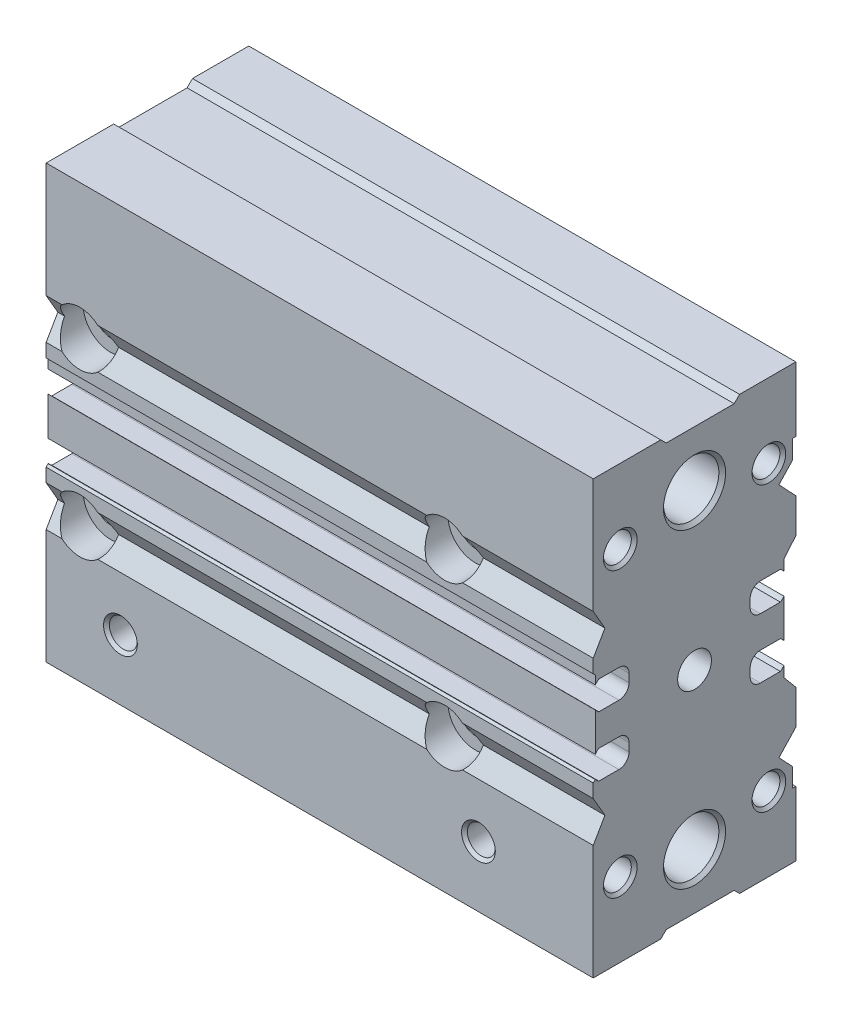
from build123d import *

# Parameters (mm, degrees)
BOSS_EXTRUDE1_DEPTH = 81
SKETCH10_W          = 50
SKETCH10_H          = 4.1


with BuildPart() as part:
    # Sketch1 → Boss-Extrude1 (new body)
    with BuildSketch(Plane(origin=(0, 0, 0), x_dir=(0, 0, -1), z_dir=(1, 0, 0))):
        with BuildLine():
            Line((-15, -32), (-5, -32))
            Line((-5, -32), (-4.2, -31.2))
            Line((-4.2, -31.2), (5.866666667, -31.2))
            Line((5.866666667, -31.2), (6.666666667, -32))
            Line((6.666666667, -32), (15, -32))
            Line((15, -32), (15, -22.434782609))
            Line((15, -22.434782609), (14.5, -22.434782609))
            Line((14.5, -22.434782609), (14.5, -19.633333333))
            Line((14.5, -19.633333333), (12.5, -17.5))
            Line((12.5, -17.5), (15, -14.833333333))
            Line((15, -14.833333333), (15, -9.714205686))
            Line((15, -9.714205686), (13.235294118, -7.611111111))
            Line((13.235294118, -7.611111111), (13.235294118, -6.044444444))
            ThreePointArc((13.235294118, -6.044444444), (12.988775356, -6.313226652), (12.706722689, -6.544444444))
            Line((12.706722689, -6.544444444), (9.735294118, -6.544444444))
            ThreePointArc((9.735294118, -6.544444444), (8.674633946, -6.105104616), (8.235294118, -5.044444444))
            Line((8.235294118, -5.044444444), (8.235294118, -3.844444444))
            ThreePointArc((8.235294118, -3.844444444), (8.674633946, -2.783784273), (9.735294118, -2.344444444))
            Line((9.735294118, -2.344444444), (12.706722689, -2.344444444))
            ThreePointArc((12.706722689, -2.344444444), (12.988775356, -2.575662237), (13.235294118, -2.844444444))
            Line((13.235294118, -2.844444444), (13.235294118, 2.844444444))
            ThreePointArc((13.235294118, 2.844444444), (12.988775356, 2.575662237), (12.706722689, 2.344444444))
            Line((12.706722689, 2.344444444), (9.735294118, 2.344444444))
            ThreePointArc((9.735294118, 2.344444444), (8.674633946, 2.783784273), (8.235294118, 3.844444444))
            Line((8.235294118, 3.844444444), (8.235294118, 5.044444444))
            ThreePointArc((8.235294118, 5.044444444), (8.674633946, 6.105104616), (9.735294118, 6.544444444))
            Line((9.735294118, 6.544444444), (12.706722689, 6.544444444))
            ThreePointArc((12.706722689, 6.544444444), (12.988775356, 6.313226652), (13.235294118, 6.044444444))
            Line((13.235294118, 6.044444444), (13.235294118, 7.611111111))
            Line((13.235294118, 7.611111111), (15, 9.714205686))
            Line((15, 9.714205686), (15, 14.833333333))
            Line((15, 14.833333333), (12.5, 17.5))
            Line((12.5, 17.5), (14.5, 19.633333333))
            Line((14.5, 19.633333333), (14.5, 22.434782609))
            Line((14.5, 22.434782609), (15, 22.434782609))
            Line((15, 22.434782609), (15, 32))
            Line((15, 32), (6.666666667, 32))
            Line((6.666666667, 32), (5.866666667, 31.2))
            Line((5.866666667, 31.2), (-4.2, 31.2))
            Line((-4.2, 31.2), (-5, 32))
            Line((-5, 32), (-15, 32))
            Line((-15, 32), (-15, 15))
            Line((-15, 15), (-13.2679, 12))
            Line((-13.2679, 12), (-15, 9))
            Line((-15, 9), (-15, 7))
            Line((-15, 7), (-14.7, 6.7))
            Line((-14.7, 6.7), (-14.7, 5.42))
            ThreePointArc((-14.7, 5.42), (-14.453481239, 5.688782207), (-14.171428571, 5.92))
            Line((-14.171428571, 5.92), (-11.2, 5.92))
            ThreePointArc((-11.2, 5.92), (-10.139339828, 5.480660172), (-9.7, 4.42))
            Line((-9.7, 4.42), (-9.7, 3.22))
            ThreePointArc((-9.7, 3.22), (-10.139339828, 2.159339828), (-11.2, 1.72))
            Line((-11.2, 1.72), (-14.171428571, 1.72))
            ThreePointArc((-14.171428571, 1.72), (-14.453481239, 1.951217793), (-14.7, 2.22))
            Line((-14.7, 2.22), (-14.7, -3.468888889))
            ThreePointArc((-14.7, -3.468888889), (-14.453481239, -3.200106681), (-14.171428571, -2.968888889))
            Line((-14.171428571, -2.968888889), (-11.2, -2.968888889))
            ThreePointArc((-11.2, -2.968888889), (-10.139339828, -3.408228717), (-9.7, -4.468888889))
            Line((-9.7, -4.468888889), (-9.7, -5.668888889))
            ThreePointArc((-9.7, -5.668888889), (-10.139339828, -6.729549061), (-11.2, -7.168888889))
            Line((-11.2, -7.168888889), (-14.171428571, -7.168888889))
            ThreePointArc((-14.171428571, -7.168888889), (-14.453481239, -6.937671096), (-14.7, -6.668888889))
            Line((-14.7, -6.668888889), (-14.7, -6.7))
            Line((-14.7, -6.7), (-15, -7))
            Line((-15, -7), (-15, -9))
            Line((-15, -9), (-13.2679, -12))
            Line((-13.2679, -12), (-15, -15))
            Line((-15, -15), (-15, -32))
        make_face()
    extrude(amount=BOSS_EXTRUDE1_DEPTH)

    # Sketch2 → Cut-Revolve1 (revolve, cut)
    with BuildSketch(Plane.XY):
        Polygon((0, 23), (0, 27.6), (0.5, 27.1), (80.5, 27.1), (81, 27.6), (81, 23), align=None)
    revolve(axis=Axis((81, 23, 0), (-1, 0, 0)), mode=Mode.SUBTRACT)

    # Sketch3 → Cut-Revolve2 (revolve, cut)
    with BuildSketch(Plane.XY):
        Polygon((0, -23), (0, -18.4), (0.5, -18.9), (80.5, -18.9), (81, -18.4), (81, -23), align=None)
    revolve(axis=Axis((81, -23, 0), (-1, 0, 0)), mode=Mode.SUBTRACT)

    # Sketch4 → Cut-Revolve3 (revolve, cut)
    with BuildSketch(Plane(origin=(0, 27, 0), x_dir=(-1, 0, 0), z_dir=(0, 1, 0))):
        Polygon((-11, -15), (-13.5, -15), (-13.067, -14.567), (-13.067, -7.093383006), (-11, -5.9), align=None)
    revolve(axis=Axis((11, 27, -5.9), (0, 0, -1)), mode=Mode.SUBTRACT)

    # Sketch5 → Cut-Revolve4 (revolve, cut)
    with BuildSketch(Plane(origin=(0, 27, 0), x_dir=(-1, 0, 0), z_dir=(0, 1, 0))):
        Polygon((-68, -15), (-70.5, -15), (-70.067, -14.567), (-70.067, -7.093383006), (-68, -5.9), align=None)
    revolve(axis=Axis((68, 27, -5.9), (0, 0, -1)), mode=Mode.SUBTRACT)

    # Sketch6 → Cut-Revolve5 (revolve, cut)
    with BuildSketch(Plane(origin=(0, -27, 0), x_dir=(-1, 0, 0), z_dir=(0, 1, 0))):
        Polygon((-11, -15), (-13.5, -15), (-13.067, -14.567), (-13.067, -7.093383006), (-11, -5.9), align=None)
    revolve(axis=Axis((11, -27, -5.9), (0, 0, -1)), mode=Mode.SUBTRACT)

    # Sketch7 → Cut-Revolve6 (revolve, cut)
    with BuildSketch(Plane(origin=(0, -27, 0), x_dir=(-1, 0, 0), z_dir=(0, 1, 0))):
        Polygon((-68, -15), (-70.5, -15), (-70.067, -14.567), (-70.067, -7.093383006), (-68, -5.9), align=None)
    revolve(axis=Axis((68, -27, -5.9), (0, 0, -1)), mode=Mode.SUBTRACT)

    # Sketch8 → Cut-Revolve7 (revolve, cut)
    with BuildSketch(Plane(origin=(0, -23, 0), x_dir=(-1, 0, 0), z_dir=(0, 1, 0))):
        Polygon((-11, 9.25), (-13.067, 9.25), (-13.067, 14.567), (-13.5, 15), (-11, 15), align=None)
    revolve(axis=Axis((11, -23, 15), (0, 0, -1)), mode=Mode.SUBTRACT)

    # Sketch9 → Cut-Revolve8 (revolve, cut)
    with BuildSketch(Plane(origin=(0, -23, 0), x_dir=(-1, 0, 0), z_dir=(0, 1, 0))):
        Polygon((-64, 9.25), (-66.067, 9.25), (-66.067, 14.567), (-66.5, 15), (-64, 15), align=None)
    revolve(axis=Axis((64, -23, 15), (0, 0, -1)), mode=Mode.SUBTRACT)

    # Sketch10 → Cut-Revolve9 (revolve, cut)
    with BuildSketch(Plane(origin=(0, 0, 0), x_dir=(-1, 0, 0), z_dir=(0, 1, 0))):
        with Locations((-25, -2.05)):
            Rectangle(SKETCH10_W, SKETCH10_H)
    revolve(axis=Axis((50, 0, 0), (-1, 0, 0)), mode=Mode.SUBTRACT)

    # Sketch11 → Cut-Revolve10 (revolve, cut)
    with BuildSketch(Plane(origin=(11, 0, 0), x_dir=(0, 0, -1), z_dir=(1, 0, 0))):
        Polygon((-10, -26), (-7.933, -26), (-7.933, -31.567), (-7.5, -32), (-10, -32), align=None)
    revolve(axis=Axis((11, -32, 10), (0, 1, 0)), mode=Mode.SUBTRACT)

    # Sketch12 → Cut-Revolve11 (revolve, cut)
    with BuildSketch(Plane(origin=(64, 0, 0), x_dir=(0, 0, -1), z_dir=(1, 0, 0))):
        Polygon((-10, -26), (-7.933, -26), (-7.933, -31.567), (-7.5, -32), (-10, -32), align=None)
    revolve(axis=Axis((64, -32, 10), (0, 1, 0)), mode=Mode.SUBTRACT)

    # Sketch13 → Cut-Revolve12 (revolve, cut)
    with BuildSketch(Plane.XY):
        Polygon((71.556624327, 0), (73, 2.5), (81, 2.5), (81, 0), align=None)
    revolve(axis=Axis((81, 0, 0), (-1, 0, 0)), mode=Mode.SUBTRACT)

    # Sketch14 → Cut-Revolve13 (revolve, cut)
    with BuildSketch(Plane.XY.offset(-11)):
        Polygon((66.606616994, 21), (67.8, 23.067), (80.567, 23.067), (81, 23.5), (81, 21), align=None)
    revolve(axis=Axis((81, 21, -11), (-1, 0, 0)), mode=Mode.SUBTRACT)

    # Sketch15 → Cut-Revolve14 (revolve, cut)
    with BuildSketch(Plane.XY.offset(-11)):
        Polygon((66.606616994, -21), (67.8, -18.933), (80.567, -18.933), (81, -18.5), (81, -21), align=None)
    revolve(axis=Axis((81, -21, -11), (-1, 0, 0)), mode=Mode.SUBTRACT)

    # Sketch16 → Cut-Revolve15 (revolve, cut)
    with BuildSketch(Plane.XY.offset(11)):
        Polygon((66.606616994, 21), (67.8, 23.067), (80.567, 23.067), (81, 23.5), (81, 21), align=None)
    revolve(axis=Axis((81, 21, 11), (-1, 0, 0)), mode=Mode.SUBTRACT)

    # Sketch17 → Cut-Revolve16 (revolve, cut)
    with BuildSketch(Plane.XY.offset(11)):
        Polygon((66.606616994, -21), (67.8, -18.933), (80.567, -18.933), (81, -18.5), (81, -21), align=None)
    revolve(axis=Axis((81, -21, 11), (-1, 0, 0)), mode=Mode.SUBTRACT)

    # Sketch18 → Cut-Revolve17 (revolve, cut)
    with BuildSketch(Plane(origin=(5, 0, 0), x_dir=(0, 0, -1), z_dir=(1, 0, 0))):
        Polygon((-15, 12), (-15, 16), (-10.5, 16), (-10.5, 14.15), (4.393782217, 14.15), (4.393782217, 14.067), (14.567, 14.067), (15, 14.5), (15, 12), align=None)
    revolve(axis=Axis((5, 12, -15), (0, 0, 1)), mode=Mode.SUBTRACT)

    # Sketch19 → Cut-Revolve18 (revolve, cut)
    with BuildSketch(Plane(origin=(5, 0, 0), x_dir=(0, 0, -1), z_dir=(1, 0, 0))):
        Polygon((-15, -12), (-15, -8), (-10.5, -8), (-10.5, -9.85), (4.393782217, -9.85), (4.393782217, -9.933), (14.567, -9.933), (15, -9.5), (15, -12), align=None)
    revolve(axis=Axis((5, -12, -15), (0, 0, 1)), mode=Mode.SUBTRACT)

    # Sketch20 → Cut-Revolve19 (revolve, cut)
    with BuildSketch(Plane(origin=(59, 0, 0), x_dir=(0, 0, -1), z_dir=(1, 0, 0))):
        Polygon((-15, -12), (-15, -8), (-10.5, -8), (-10.5, -9.85), (4.393782217, -9.85), (4.393782217, -9.933), (14.567, -9.933), (15, -9.5), (15, -12), align=None)
    revolve(axis=Axis((59, -12, -15), (0, 0, 1)), mode=Mode.SUBTRACT)

    # Sketch21 → Cut-Revolve20 (revolve, cut)
    with BuildSketch(Plane(origin=(59, 0, 0), x_dir=(0, 0, -1), z_dir=(1, 0, 0))):
        Polygon((-15, 12), (-15, 16), (-10.5, 16), (-10.5, 14.15), (4.393782217, 14.15), (4.393782217, 14.067), (14.567, 14.067), (15, 14.5), (15, 12), align=None)
    revolve(axis=Axis((59, 12, -15), (0, 0, 1)), mode=Mode.SUBTRACT)


solid = part.part
